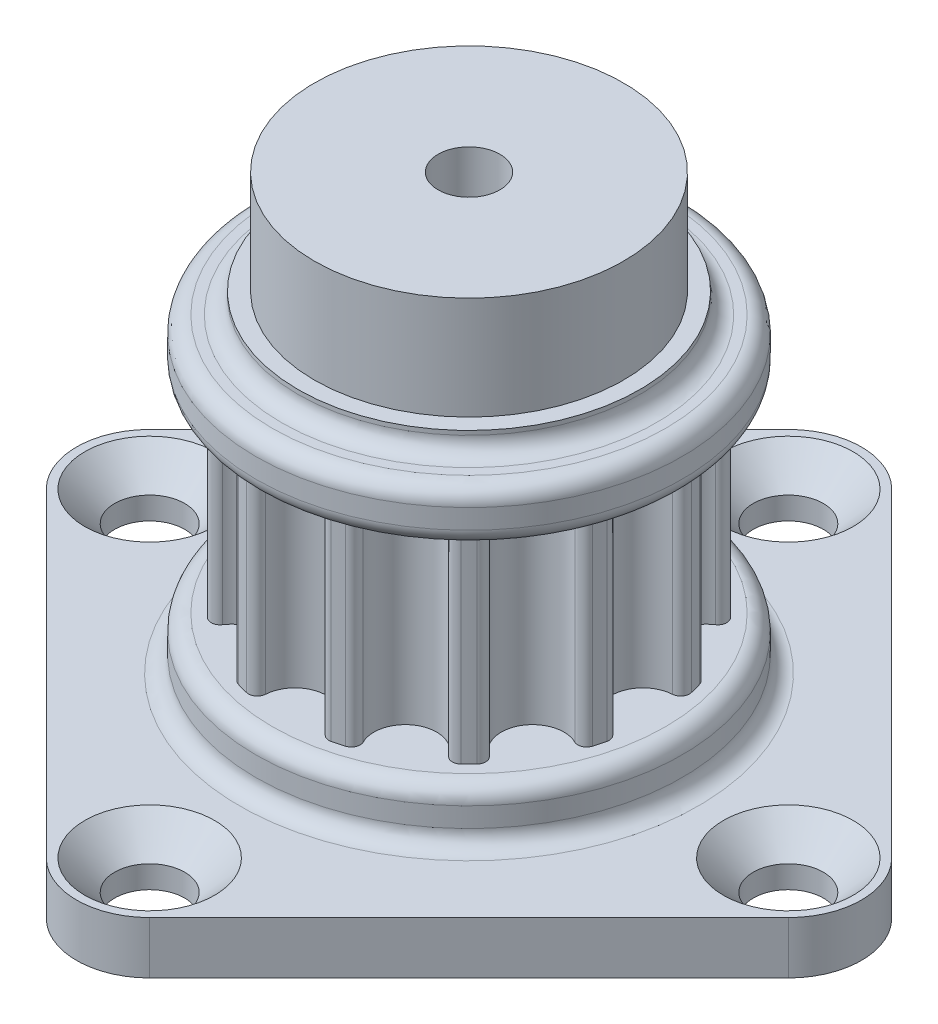
from build123d import *

# Parameters (mm, degrees)
BOSS_EXTRUDE1_DEPTH                            = 5.000000033
CIRPATTERN1_COUNT                              = 12
SKETCH2_R                                      = 10.343109616000001
BOSS_EXTRUDE2_DEPTH                            = 2.54
SKETCH4_R                                      = 19.05
SKETCH4_R_2                                    = 1.2700000000000011
BOSS_EXTRUDE3_DEPTH                            = 2.54
CUT_EXTRUDE2_DEPTH                             = 31.874121882096663
CUT_EXTRUDE2_DEPTH_BACK                        = 31.874121882096663
SKETCH6_R                                      = 1.2700000000000016
SKETCH6_R_2                                    = 1.2700000000000011
CSK_FOR_M3_FLAT_HEAD_MACHINE_SCREW1_AT_2_COUNT = 2
CSK_FOR_M3_FLAT_HEAD_MACHINE_SCREW1_AT_2_PITCH = 21.920310216782973
CSK_FOR_M3_FLAT_HEAD_MACHINE_SCREW1_AT_3_COUNT = 2
CSK_FOR_M3_FLAT_HEAD_MACHINE_SCREW1_AT_3_PITCH = 31
CSK_FOR_M3_FLAT_HEAD_MACHINE_SCREW1_AT_4_COUNT = 2
CSK_FOR_M3_FLAT_HEAD_MACHINE_SCREW1_AT_4_PITCH = 21.920310216782973
SKETCH8_R                                      = 7.499999986
SKETCH8_R_2                                    = 1.500000048
BOSS_EXTRUDE4_DEPTH                            = 5.999999937999999
SKETCH9_R                                      = 8.293749985999998
BOSS_EXTRUDE5_DEPTH                            = 1.0000000320000002
CUT_EXTRUDE_THIN1_DEPTH                        = 36.82889057993507
CUT_EXTRUDE1_DEPTH                             = 31.15189213324232
CUT_EXTRUDE1_DEPTH_BACK                        = 31.15189213324232
SKETCH5_R                                      = 1.5
FILLET1_R                                      = 0.79375


with BuildPart() as part:
    # Sketch1 → Boss-Extrude1 (new, symmetric)
    with BuildSketch(Plane(origin=(0, 0, 0), x_dir=(1, 0, 0), z_dir=(0, 1, 0))):
        with BuildLine():
            ThreePointArc((0, 6.9178596720000005), (1.044521548379475, 7.331734236544828), (1.5220910947127906, 8.348712480472011))
            ThreePointArc((1.5220910947127906, 8.348712480472011), (1.6946985083597814, 8.667232123788082), (2.049429416913147, 8.740812453639233))
            ThreePointArc((2.049429416913147, 8.740812453639233), (2.3236410528776097, 8.671946467892056), (2.5955482885097134, 8.594480343023537))
            ThreePointArc((2.5955482885097134, 8.594480343023537), (2.8659641018988875, 8.353392453876918), (2.8561866853406714, 7.991242644337345))
            ThreePointArc((2.8561866853406714, 7.991242644337345), (2.761284922575541, 6.871728876833661), (3.4589298360000074, 5.99104221576788))
            ThreePointArc((3.4589298360000074, 5.99104221576788), (-1.7904738344602829, -6.682139319828422), (0, 6.9178596720000005))
        make_face()
    boss_extrude1 = extrude(amount=BOSS_EXTRUDE1_DEPTH, both=True)

    # CirPattern1: Boss-Extrude1 ×12 about axis
    cirpattern1_axis = Axis((0, 3.3, 0), (0, -1, 0))
    for i in range(1, CIRPATTERN1_COUNT):
        add(boss_extrude1.rotate(cirpattern1_axis, i * 360 / CIRPATTERN1_COUNT))

    # Sketch2 → Boss-Extrude2 (add)
    with BuildSketch(Plane.XZ.offset(5.000000033)):
        Circle(SKETCH2_R)
    boss_extrude2 = extrude(amount=BOSS_EXTRUDE2_DEPTH)

    # Mirror1: Boss-Extrude2 across plane
    add(boss_extrude2.mirror(Plane.ZX))

    # Sketch4 → Boss-Extrude3 (add)
    with BuildSketch(Plane.XZ.offset(7.540000033)):
        Circle(SKETCH4_R)
        with Locations((-15.5, 0)):
            Circle(SKETCH4_R_2, mode=Mode.SUBTRACT)
    extrude(amount=BOSS_EXTRUDE3_DEPTH)

    # Sketch6 → Cut-Extrude2 (cut, two sides: drawn at the far end of the back side and taken through both)
    with BuildSketch(Plane(origin=(0, -7.540000033, 0), x_dir=(1, 0, 0), z_dir=(0, 1, 0)).offset(-CUT_EXTRUDE2_DEPTH_BACK)):
        with Locations((0, -15.5)):
            Circle(SKETCH6_R)
        with Locations((15.5, 0)):
            Circle(SKETCH6_R_2)
        with Locations((0, 15.5)):
            Circle(SKETCH6_R)
        with Locations((-15.5, 0)):
            Circle(SKETCH6_R_2)
    extrude(amount=CUT_EXTRUDE2_DEPTH + CUT_EXTRUDE2_DEPTH_BACK, mode=Mode.SUBTRACT)

    # Sketch7 → CSK for M3 Flat Head Machine Screw1 (revolve, cut)
    with BuildSketch(Plane(origin=(-15.5, -7.540000033, 0), x_dir=(0, 0, 1), z_dir=(1, 0, 0))):
        Polygon((0, 0), (-6.2e-16, 2.5400000000000005), (1.6999999999999982, 2.5400000000000005), (1.6999999999999984, 1.4500000000000017), (3.15, -1.73e-15), align=None)
    csk_for_m3_flat_head_machine_screw1 = revolve(axis=Axis((-15.5, -1.1900000330000093, 0), (0, -1, 0)), mode=Mode.SUBTRACT)

    # CSK for M3 Flat Head Machine Screw1 at 2: CSK for M3 Flat Head Machine Screw1 ×2
    with Locations(*[Vector(0.7071067811865476, 0, 0.7071067811865476) * (i * CSK_FOR_M3_FLAT_HEAD_MACHINE_SCREW1_AT_2_PITCH) for i in range(1, CSK_FOR_M3_FLAT_HEAD_MACHINE_SCREW1_AT_2_COUNT)]):
        add(csk_for_m3_flat_head_machine_screw1, mode=Mode.SUBTRACT)

    # CSK for M3 Flat Head Machine Screw1 at 3: CSK for M3 Flat Head Machine Screw1 ×2
    with Locations(*[(i * CSK_FOR_M3_FLAT_HEAD_MACHINE_SCREW1_AT_3_PITCH, 0, 0) for i in range(1, CSK_FOR_M3_FLAT_HEAD_MACHINE_SCREW1_AT_3_COUNT)]):
        add(csk_for_m3_flat_head_machine_screw1, mode=Mode.SUBTRACT)

    # CSK for M3 Flat Head Machine Screw1 at 4: CSK for M3 Flat Head Machine Screw1 ×2
    with Locations(*[Vector(0.7071067811865476, 0, -0.7071067811865476) * (i * CSK_FOR_M3_FLAT_HEAD_MACHINE_SCREW1_AT_4_PITCH) for i in range(1, CSK_FOR_M3_FLAT_HEAD_MACHINE_SCREW1_AT_4_COUNT)]):
        add(csk_for_m3_flat_head_machine_screw1, mode=Mode.SUBTRACT)

    # Sketch8 → Boss-Extrude4 (add)
    with BuildSketch(Plane(origin=(0, 7.540000033, 0), x_dir=(1, 0, 0), z_dir=(0, 1, 0))):
        Circle(SKETCH8_R)
        Circle(SKETCH8_R_2, mode=Mode.SUBTRACT)
    extrude(amount=BOSS_EXTRUDE4_DEPTH)

    # Sketch9 → Boss-Extrude5 (add)
    with BuildSketch(Plane(origin=(0, 7.540000033, 0), x_dir=(1, 0, 0), z_dir=(0, 1, 0))):
        Circle(SKETCH9_R)
    extrude(amount=BOSS_EXTRUDE5_DEPTH)

    # Sketch10 → Cut-Extrude-Thin1 (cut, through all)
    with BuildSketch(Plane(origin=(0, -10.080000033000001, 0), x_dir=(-1, 0, 0), z_dir=(0, -1, 0))):
        with BuildLine():
            Line((35.970741315350544, 20.47074131535056), (20.470741315350537, 35.97074131535055))
            ThreePointArc((20.4707413153505, 35.970741315350594), (2.204e-14, 44.44999999999999), (-20.470741315350477, 35.97074131535062))
            Line((-20.47074131535056, 35.970741315350544), (-35.97074131535056, 20.470741315350534))
            ThreePointArc((-35.97074131535053, 20.47074131535056), (-44.45, -7.34e-15), (-35.97074131535053, -20.470741315350555))
            Line((-35.970741315350544, -20.470741315350566), (-20.470741315350544, -35.97074131535056))
            ThreePointArc((-20.47074131535049, -35.970741315350615), (-1.207e-14, -44.45), (20.470741315350484, -35.970741315350644))
            Line((20.470741315350566, -35.97074131535055), (35.97074131535056, -20.470741315350537))
            ThreePointArc((35.97074131535053, -20.470741315350537), (44.45, 1.125e-14), (35.97074131535053, 20.47074131535057))
        make_face()
        with BuildLine():
            Line((18.010229073212244, 2.5102290732122454), (2.5102290732122388, 18.01022907321224))
            ThreePointArc((2.5102290732122388, 18.01022907321224), (-2.86e-15, 19.049999999999994), (-2.5102290732122445, 18.010229073212244))
            Line((-2.5102290732122445, 18.010229073212244), (-18.010229073212244, 2.5102290732122343))
            ThreePointArc((-18.010229073212244, 2.5102290732122343), (-19.050000000000004, -1.045e-14), (-18.010229073212244, -2.510229073212254))
            Line((-18.010229073212244, -2.510229073212254), (-2.5102290732122436, -18.010229073212248))
            ThreePointArc((-2.5102290732122436, -18.010229073212248), (3.3e-15, -19.05), (2.5102290732122516, -18.01022907321225))
            Line((2.5102290732122516, -18.01022907321225), (18.010229073212244, -2.510229073212242))
            ThreePointArc((18.010229073212244, -2.510229073212242), (19.050000000000004, 1.18e-15), (18.010229073212244, 2.5102290732122454))
        make_face(mode=Mode.SUBTRACT)
    extrude(amount=-CUT_EXTRUDE_THIN1_DEPTH, mode=Mode.SUBTRACT)

    # Sketch5 → Cut-Extrude1 (cut, two sides: drawn at the far end of the back side and taken through both)
    with BuildSketch(Plane(origin=(0, 0, 0), x_dir=(1, 0, 0), z_dir=(0, 1, 0)).offset(-CUT_EXTRUDE1_DEPTH_BACK)):
        Circle(SKETCH5_R)
    extrude(amount=CUT_EXTRUDE1_DEPTH + CUT_EXTRUDE1_DEPTH_BACK, mode=Mode.SUBTRACT)

    # Fillet1
    fillet1_edges = [part.edges().sort_by_distance(p)[0] for p in [
        (-10.343109616000001, -7.540000033, 5.86e-15),
        (-10.343109616000001, -5.000000033, 5.86e-15),
        (-10.343109616000001, 5.000000033, 5.86e-15),
        (-10.343109616000001, 7.540000033, 5.86e-15),
        (-8.293749985999998, 7.540000033, -1.02e-15),
    ]]
    fillet(fillet1_edges, radius=FILLET1_R)


solid = part.part
